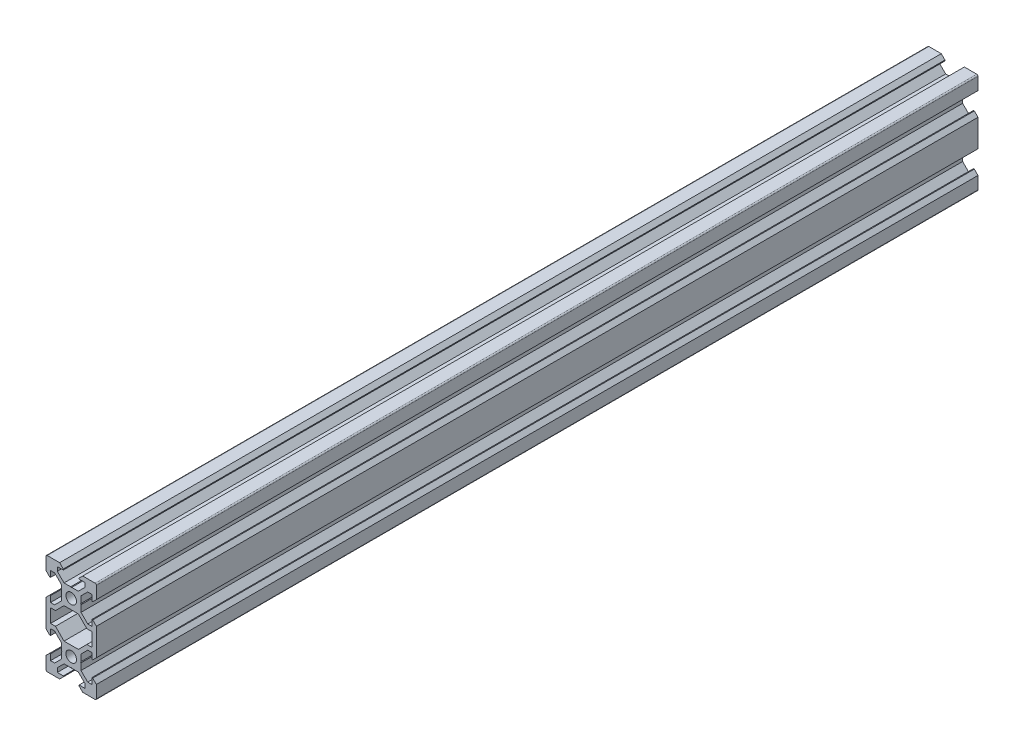
from build123d import *

# Parameters (mm, degrees)
SKETCH1_R           = 2.1
BOSS_EXTRUDE1_DEPTH = 350


with BuildPart() as part:
    # Sketch1 → Boss-Extrude1 (new body)
    with BuildSketch(Plane.XY):
        with BuildLine():
            Line((4.58, -20), (9.5, -20))
            ThreePointArc((9.5, -20), (9.853553391, -19.853553391), (10, -19.5))
            Line((10, -19.5), (10, -14.58))
            Line((10, -14.58), (8.545, -13.125))
            Line((8.545, -13.125), (8.2, -13.125))
            Line((8.2, -13.125), (8.2, -15.5))
            Line((8.2, -15.5), (6.560660172, -15.5))
            Line((6.560660172, -15.5), (3.9, -12.839339828))
            Line((3.9, -12.839339828), (3.9, -10.21))
            Line((3.9, -10.21), (3.69, -10))
            Line((3.69, -10), (3.9, -9.79))
            Line((3.9, -9.79), (3.9, -7.160660172))
            Line((3.9, -7.160660172), (6.560660172, -4.5))
            Line((6.560660172, -4.5), (8.2, -4.5))
            Line((8.2, -4.5), (8.2, -6.875))
            Line((8.2, -6.875), (8.545, -6.875))
            Line((8.545, -6.875), (10, -5.42))
            Line((10, -5.42), (10, 5.42))
            Line((10, 5.42), (8.545, 6.875))
            Line((8.545, 6.875), (8.2, 6.875))
            Line((8.2, 6.875), (8.2, 4.5))
            Line((8.2, 4.5), (6.560660172, 4.5))
            Line((6.560660172, 4.5), (3.9, 7.160660172))
            Line((3.9, 7.160660172), (3.9, 9.79))
            Line((3.9, 9.79), (3.69, 10))
            Line((3.69, 10), (3.9, 10.21))
            Line((3.9, 10.21), (3.9, 12.839339828))
            Line((3.9, 12.839339828), (6.560660172, 15.5))
            Line((6.560660172, 15.5), (8.2, 15.5))
            Line((8.2, 15.5), (8.2, 13.125))
            Line((8.2, 13.125), (8.545, 13.125))
            Line((8.545, 13.125), (10, 14.58))
            Line((10, 14.58), (10, 19.5))
            ThreePointArc((10, 19.5), (9.853553391, 19.853553391), (9.5, 20))
            Line((9.5, 20), (4.58, 20))
            Line((4.58, 20), (3.125, 18.545))
            Line((3.125, 18.545), (3.125, 18.2))
            Line((3.125, 18.2), (5.5, 18.2))
            Line((5.5, 18.2), (5.5, 16.560660172))
            Line((5.5, 16.560660172), (2.839339828, 13.9))
            Line((2.839339828, 13.9), (0.21, 13.9))
            Line((0.21, 13.9), (0, 13.69))
            Line((0, 13.69), (-0.21, 13.9))
            Line((-0.21, 13.9), (-2.839339828, 13.9))
            Line((-2.839339828, 13.9), (-5.5, 16.560660172))
            Line((-5.5, 16.560660172), (-5.5, 18.2))
            Line((-5.5, 18.2), (-3.125, 18.2))
            Line((-3.125, 18.2), (-3.125, 18.545))
            Line((-3.125, 18.545), (-4.58, 20))
            Line((-4.58, 20), (-9.5, 20))
            ThreePointArc((-9.5, 20), (-9.853553391, 19.853553391), (-10, 19.5))
            Line((-10, 19.5), (-10, 14.58))
            Line((-10, 14.58), (-8.545, 13.125))
            Line((-8.545, 13.125), (-8.2, 13.125))
            Line((-8.2, 13.125), (-8.2, 15.5))
            Line((-8.2, 15.5), (-6.560660172, 15.5))
            Line((-6.560660172, 15.5), (-3.9, 12.839339828))
            Line((-3.9, 12.839339828), (-3.9, 10.21))
            Line((-3.9, 10.21), (-3.69, 10))
            Line((-3.69, 10), (-3.9, 9.79))
            Line((-3.9, 9.79), (-3.9, 7.160660172))
            Line((-3.9, 7.160660172), (-6.560660172, 4.5))
            Line((-6.560660172, 4.5), (-8.2, 4.5))
            Line((-8.2, 4.5), (-8.2, 6.875))
            Line((-8.2, 6.875), (-8.545, 6.875))
            Line((-8.545, 6.875), (-10, 5.42))
            Line((-10, 5.42), (-10, -5.42))
            Line((-10, -5.42), (-8.545, -6.875))
            Line((-8.545, -6.875), (-8.2, -6.875))
            Line((-8.2, -6.875), (-8.2, -4.5))
            Line((-8.2, -4.5), (-6.560660172, -4.5))
            Line((-6.560660172, -4.5), (-3.9, -7.160660172))
            Line((-3.9, -7.160660172), (-3.9, -9.79))
            Line((-3.9, -9.79), (-3.69, -10))
            Line((-3.69, -10), (-3.9, -10.21))
            Line((-3.9, -10.21), (-3.9, -12.839339828))
            Line((-3.9, -12.839339828), (-6.560660172, -15.5))
            Line((-6.560660172, -15.5), (-8.2, -15.5))
            Line((-8.2, -15.5), (-8.2, -13.125))
            Line((-8.2, -13.125), (-8.545, -13.125))
            Line((-8.545, -13.125), (-10, -14.58))
            Line((-10, -14.58), (-10, -19.5))
            ThreePointArc((-10, -19.5), (-9.853553391, -19.853553391), (-9.5, -20))
            Line((-9.5, -20), (-4.58, -20))
            Line((-4.58, -20), (-3.125, -18.545))
            Line((-3.125, -18.545), (-3.125, -18.2))
            Line((-3.125, -18.2), (-5.5, -18.2))
            Line((-5.5, -18.2), (-5.5, -16.560660172))
            Line((-5.5, -16.560660172), (-2.839339828, -13.9))
            Line((-2.839339828, -13.9), (-0.21, -13.9))
            Line((-0.21, -13.9), (0, -13.69))
            Line((0, -13.69), (0.21, -13.9))
            Line((0.21, -13.9), (2.839339828, -13.9))
            Line((2.839339828, -13.9), (5.5, -16.560660172))
            Line((5.5, -16.560660172), (5.5, -18.2))
            Line((5.5, -18.2), (3.125, -18.2))
            Line((3.125, -18.2), (3.125, -18.545))
            Line((3.125, -18.545), (4.58, -20))
        make_face()
        with Locations((0, -10)):
            Circle(SKETCH1_R, mode=Mode.SUBTRACT)
        Polygon((-6.239339828, -2.7), (-8.2, -2.7), (-8.2, 2.7), (-6.239339828, 2.7), (-2.839339828, 6.1), (2.839339828, 6.1), (6.239339828, 2.7), (8.2, 2.7), (8.2, -2.7), (6.239339828, -2.7), (2.839339828, -6.1), (-2.839339828, -6.1), align=None, mode=Mode.SUBTRACT)
        with Locations((0, 10)):
            Circle(SKETCH1_R, mode=Mode.SUBTRACT)
    extrude(amount=BOSS_EXTRUDE1_DEPTH)


solid = part.part
